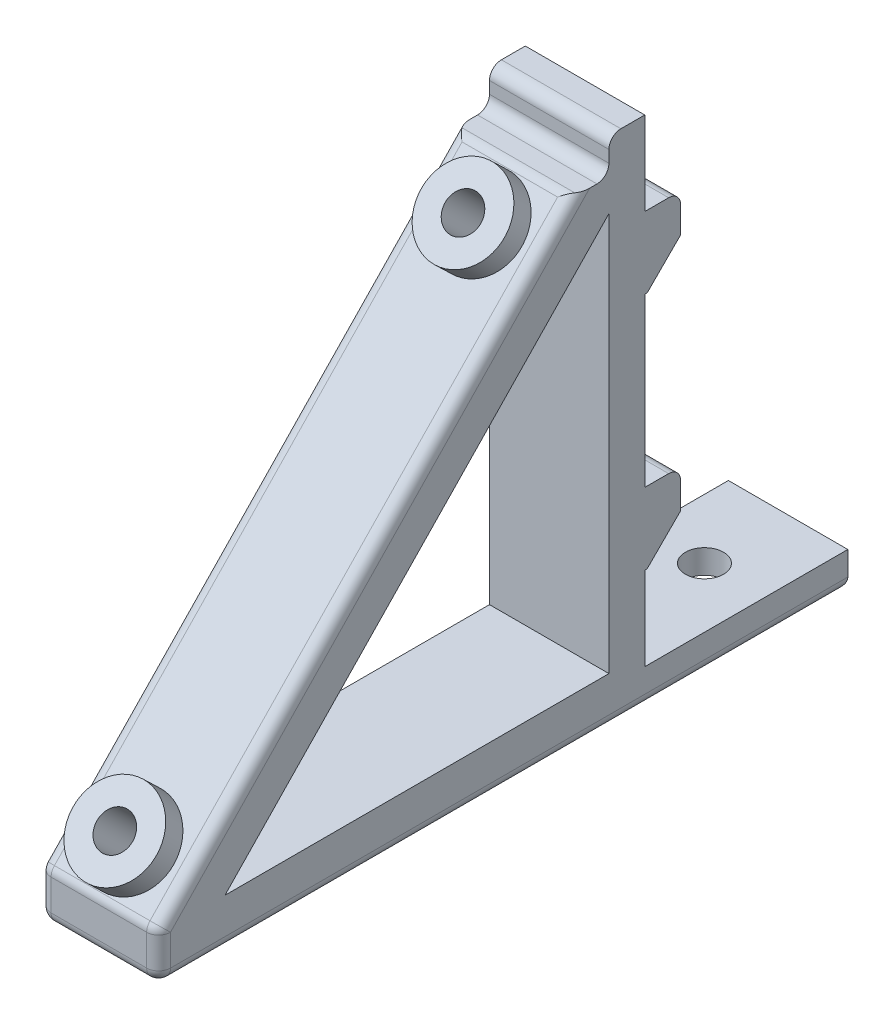
from build123d import *

# Parameters (mm, degrees)
SKETCH1_W           = 10
SKETCH1_H           = 20
BOSS_EXTRUDE1_DEPTH = 3
SKETCH2_R           = 1.6
CUT_EXTRUDE1_DEPTH  = 4
SKETCH3_R           = 3.1
CUT_EXTRUDE2_DEPTH  = 1
SKETCH4_W           = 10
SKETCH4_H           = 43
BOSS_EXTRUDE2_DEPTH = 3
SKETCH5_W           = 10
SKETCH5_H           = 6
BOSS_EXTRUDE3_DEPTH = 3
CHAMFER1_SIZE       = 2.8
BOSS_EXTRUDE4_DEPTH = 10
SKETCH7_R           = 3.5
BOSS_EXTRUDE5_DEPTH = 2
SKETCH10_W          = 10
SKETCH10_H          = 3
CUT_EXTRUDE6_DEPTH  = 4
FILLET2_R           = 1
SKETCH8_R           = 1.5
CUT_EXTRUDE4_DEPTH  = 6


with BuildPart() as part:
    # Sketch1 → Boss-Extrude1 (new body)
    with BuildSketch(Plane(origin=(0, 0, 0), x_dir=(1, 0, 0), z_dir=(0, 1, 0))):
        Rectangle(SKETCH1_W, SKETCH1_H)
    extrude(amount=BOSS_EXTRUDE1_DEPTH)

    # Sketch2 → Cut-Extrude1 (cut, through all)
    with BuildSketch(Plane.XZ):
        Circle(SKETCH2_R)
    extrude(amount=-CUT_EXTRUDE1_DEPTH, mode=Mode.SUBTRACT)

    # Sketch3 → Cut-Extrude2 (cut)
    with BuildSketch(Plane.XZ):
        Circle(SKETCH3_R)
    extrude(amount=-CUT_EXTRUDE2_DEPTH, mode=Mode.SUBTRACT)

    # Sketch4 → Boss-Extrude2 (add)
    with BuildSketch(Plane.XY.offset(10)):
        with Locations((0, 21.5)):
            Rectangle(SKETCH4_W, SKETCH4_H)
    extrude(amount=BOSS_EXTRUDE2_DEPTH)

    # Sketch5 → Boss-Extrude3 (add)
    with BuildSketch(Plane(origin=(0, 0, 10), x_dir=(-1, 0, 0), z_dir=(0, 0, -1))):
        with Locations((0, 13)):
            Rectangle(SKETCH5_W, SKETCH5_H)
        with Locations((0, 33)):
            Rectangle(SKETCH5_W, SKETCH5_H)
    extrude(amount=BOSS_EXTRUDE3_DEPTH)

    # Chamfer1
    chamfer1_edges = [part.edges().sort_by_distance(p)[0] for p in [
        (0, 30, 7),
        (0, 10, 7),
    ]]
    chamfer(chamfer1_edges, length=CHAMFER1_SIZE)

    # Sketch6 → Boss-Extrude4 (add)
    with BuildSketch(Plane.ZY.offset(5)):
        Polygon((13, 40), (16, 40), (50.698703146, 4), (50.698703146, 0), (13, 0), (13, 4), (45.14314759, 4), (13, 37.348604079), align=None)
    extrude(amount=-BOSS_EXTRUDE4_DEPTH)

    # Sketch7 → Boss-Extrude5 (add)
    with BuildSketch(Plane(origin=(0, -24.3220742, 77.997015511), x_dir=(1, 0, 0), z_dir=(0, -0.693974063, -0.72))):
        with Locations((0, -43.336214167)):
            Circle(SKETCH7_R)
        with Locations((0, -85.336214167)):
            Circle(SKETCH7_R)
    extrude(amount=-BOSS_EXTRUDE5_DEPTH)

    # Sketch10 → Cut-Extrude6 (cut, through all)
    with BuildSketch(Plane(origin=(0, 3, 0), x_dir=(1, 0, 0), z_dir=(0, 1, 0))):
        with Locations((0, 8.5)):
            Rectangle(SKETCH10_W, SKETCH10_H)
    extrude(amount=-CUT_EXTRUDE6_DEPTH, mode=Mode.SUBTRACT)

    # Fillet2
    fillet2_edges = [part.edges().sort_by_distance(p)[0] for p in [
        (-5, 0, 21.849351573),
        (0, 0, -7),
        (0, 43, 13),
        (0, 36, 7),
        (5, 0, 21.849351573),
        (0, 16, 7),
        (0, 40, 13),
        (0, 40, 16),
        (0, 4, 50.698703146),
        (0, 0, 50.698703146),
        (-5, 2, 50.698703146),
        (-5, 22, 33.349351573),
        (5, 22, 33.349351573),
        (5, 2, 50.698703146),
    ]]
    fillet(fillet2_edges, radius=FILLET2_R)

    # Sketch8 → Cut-Extrude4 (cut)
    with BuildSketch(Plane(origin=(0, 28.646529331, 29.720853012), x_dir=(-1, 0, 0), z_dir=(0, 0.693974063, 0.72))):
        with Locations((0, 28.303585007)):
            Circle(SKETCH8_R)
        with Locations((0, -13.696414993)):
            Circle(SKETCH8_R)
    extrude(amount=-CUT_EXTRUDE4_DEPTH, mode=Mode.SUBTRACT)


solid = part.part
